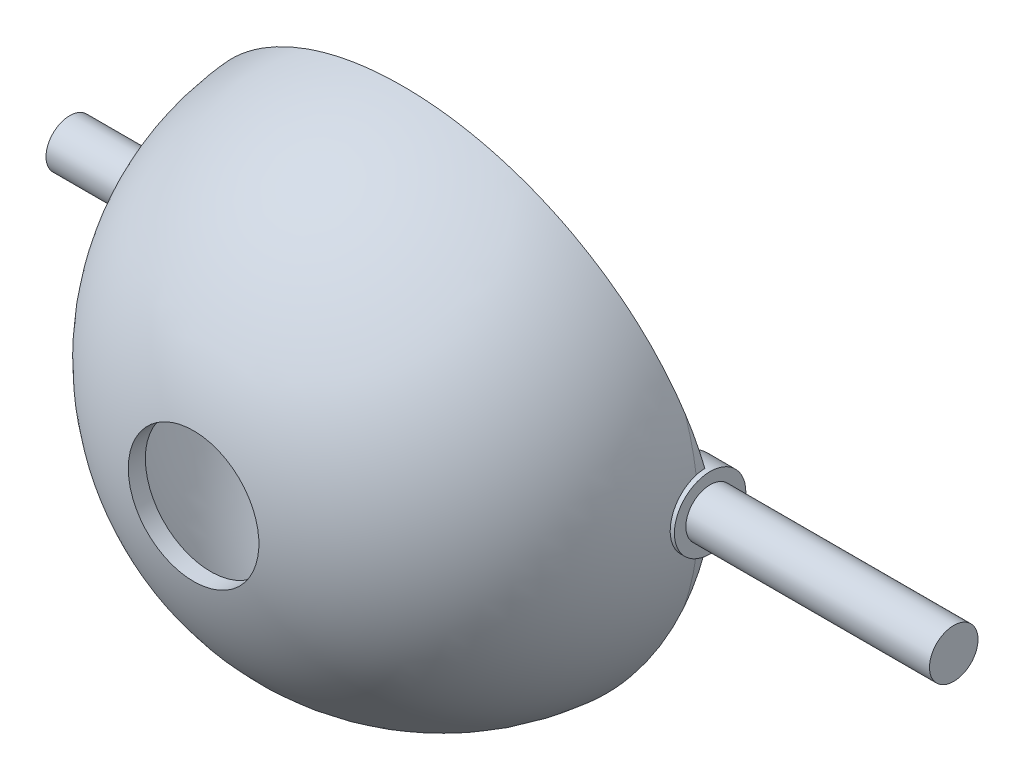
from build123d import *

# Parameters (mm, degrees)
SKETCH1_R                = 27.950000404747612
BOSS_EXTRUDE1_DEPTH      = 27.62022143637803
FILLET1_R                = 26.669999999999998
SHELL1_T                 = -1.778
SKETCH3_W                = 2.9777815367923886
SKETCH3_H                = 2.754447921533147
BOSS_EXTRUDE3_DEPTH      = 1.0160000000000005
BOSS_EXTRUDE4_DEPTH      = 25.790262530441638
BOSS_EXTRUDE4_DEPTH_BACK = 68.76087696461775
SKETCH4_R                = 3.820330599325679
SKETCH5_R                = 1.057927548072599
CUT_EXTRUDE1_DEPTH       = 74.422
SKETCH6_R                = 4.452679147341358
SKETCH6_R_2              = 2.5418565333404075
CUT_EXTRUDE2_DEPTH       = 12.446000000000002
SKETCH7_R                = 4.579796813302263
SKETCH7_R_2              = 2.5953263058571228
CUT_EXTRUDE3_DEPTH       = 26.058039102835256
CUT_EXTRUDE4_DEPTH       = 8.128000000000002
CUT_EXTRUDE4_DEPTH_BACK  = 4.571999999999997
SKETCH9_R                = 25.327508303904953
SKETCH10_R               = 6.985
CUT_EXTRUDE5_DEPTH       = 5.588
SKETCH11_R               = 0.9576542174699331
BOSS_EXTRUDE5_DEPTH      = 22.860000000000024
SKETCH12_R               = 3.048000000000001
BOSS_EXTRUDE6_DEPTH      = 11.36288626791476
BOSS_EXTRUDE6_2_DEPTH    = 11.36288626791476
SKETCH14_R               = 2.111885876285839
CUT_EXTRUDE6_DEPTH       = 33.27400000000001
CUT_EXTRUDE7_DEPTH       = 85.27832842042368
CUT_EXTRUDE8_DEPTH       = 91.8819256451622
BOSS_EXTRUDE7_DEPTH      = 4.3180000000000005
BOSS_EXTRUDE8_DEPTH      = 4.571999999999999


with BuildPart() as part:
    # Sketch1 → Boss-Extrude1 (new body)
    with BuildSketch(Plane.XY):
        Circle(SKETCH1_R)
    extrude(amount=BOSS_EXTRUDE1_DEPTH)

    # Fillet1
    fillet1_edges = [part.edges().sort_by_distance(p)[0] for p in [
        (-27.950000404747612, 3.42e-15, 27.62022143637803),
    ]]
    fillet(fillet1_edges, radius=FILLET1_R)

    # Shell1
    shell1_openings = [part.faces().sort_by_distance(p)[0] for p in [
        (0, 0, 0),
    ]]
    offset(amount=SHELL1_T, openings=shell1_openings, kind=Kind.INTERSECTION)

    # Sketch3 → Boss-Extrude3 (add)
    with BuildSketch(Plane(origin=(0, 0, 0), x_dir=(-1, 0, 0), z_dir=(0, 0, -1))):
        with Locations((-27.023367446390857, 0)):
            Rectangle(SKETCH3_W, SKETCH3_H)
    extrude(amount=BOSS_EXTRUDE3_DEPTH)

    # Sketch4 → Boss-Extrude4 (add, two sides: drawn at the far end of the back side and taken through both)
    with BuildSketch(Plane(origin=(28.51225821478705, 0, 0), x_dir=(0, 0, -1), z_dir=(1, 0, 0)).offset(-BOSS_EXTRUDE4_DEPTH_BACK)):
        Circle(SKETCH4_R)
    extrude(amount=BOSS_EXTRUDE4_DEPTH + BOSS_EXTRUDE4_DEPTH_BACK)

    # Sketch5 → Cut-Extrude1 (cut)
    with BuildSketch(Plane.ZY.offset(40.2486187498307)):
        Circle(SKETCH5_R)
    extrude(amount=-CUT_EXTRUDE1_DEPTH, mode=Mode.SUBTRACT)

    # Sketch6 → Cut-Extrude2 (cut)
    with BuildSketch(Plane.ZY.offset(40.2486187498307)):
        Circle(SKETCH6_R)
        Circle(SKETCH6_R_2, mode=Mode.SUBTRACT)
    extrude(amount=-CUT_EXTRUDE2_DEPTH, mode=Mode.SUBTRACT)

    # Sketch7 → Cut-Extrude3 (cut)
    with BuildSketch(Plane(origin=(54.30252074522868, 0, 0), x_dir=(0, 0, -1), z_dir=(1, 0, 0))):
        Circle(SKETCH7_R)
        Circle(SKETCH7_R_2, mode=Mode.SUBTRACT)
    extrude(amount=-CUT_EXTRUDE3_DEPTH, mode=Mode.SUBTRACT)

    # Sketch9 → Cut-Extrude4 (cut, two sides: drawn at the far end of the back side and taken through both)
    with BuildSketch(Plane(origin=(0, 0, 0), x_dir=(-1, 0, 0), z_dir=(0, 0, -1)).offset(-CUT_EXTRUDE4_DEPTH_BACK)):
        Circle(SKETCH9_R)
    extrude(amount=CUT_EXTRUDE4_DEPTH + CUT_EXTRUDE4_DEPTH_BACK, mode=Mode.SUBTRACT)

    # Sketch10 → Cut-Extrude5 (cut)
    with BuildSketch(Plane.XY.offset(27.62022143637803)):
        with Locations(Location((0, 0, 0), (0, 0, 180))):
            Circle(SKETCH10_R)
    extrude(amount=-CUT_EXTRUDE5_DEPTH, mode=Mode.SUBTRACT)

    # Sketch15 → Cut-Extrude7 (cut)
    with BuildSketch(Plane(origin=(54.30252074522868, 0, 0), x_dir=(0, 0, -1), z_dir=(1, 0, 0))):
        Polygon((-1.334e-14, 3.8203305993256875), (-4.891274508363616, 29.145036791355672), (1.6598448725796273, 29.145036791355672), align=None)
    extrude(amount=-CUT_EXTRUDE7_DEPTH, mode=Mode.SUBTRACT)

    # Sketch16 → Cut-Extrude8 (cut)
    with BuildSketch(Plane(origin=(54.30252074522868, 0, 0), x_dir=(0, 0, -1), z_dir=(1, 0, 0))):
        Polygon((0, -3.820330599325679), (-4.288923829809152, -28.486260213313365), (3.8203305993256866, -28.486260213313365), align=None)
    extrude(amount=-CUT_EXTRUDE8_DEPTH, mode=Mode.SUBTRACT)



with BuildPart() as body_2:
    # Sketch11 → Boss-Extrude5 (new body)
    with BuildSketch(Plane.XY.offset(27.00289653161864)):
        Circle(SKETCH11_R)
    extrude(amount=-BOSS_EXTRUDE5_DEPTH)

    # Sketch14 → Cut-Extrude6 (cut)
    with BuildSketch(Plane(origin=(0, 0, 0), x_dir=(-1, 0, 0), z_dir=(0, 0, -1))):
        Circle(SKETCH14_R)
    extrude(amount=-CUT_EXTRUDE6_DEPTH, mode=Mode.SUBTRACT)


with BuildPart() as body_3:
    # Sketch12 → Boss-Extrude6 (new body)
    with BuildSketch(Plane(origin=(0, 0, 4.142896531618617), x_dir=(-1, 0, 0), z_dir=(0, 0, -1))):
        with Locations((11.937999999999999, 16.638354336827483)):
            Circle(SKETCH12_R)
    extrude(amount=-BOSS_EXTRUDE6_DEPTH)


with BuildPart() as body_4:
    # Sketch12 → Boss-Extrude6 2 (new body)
    with BuildSketch(Plane(origin=(0, 0, 4.142896531618617), x_dir=(-1, 0, 0), z_dir=(0, 0, -1))):
        with Locations((-11.953495285116952, -16.63835433682737)):
            Circle(SKETCH12_R)
    extrude(amount=-BOSS_EXTRUDE6_2_DEPTH)


with BuildPart() as part_1:
    add(part.part)

    add(body_3.part)  # Boss-Extrude7 merges body 3
    # Sketch17 → Boss-Extrude7 (add)
    with BuildSketch(Plane(origin=(0, 0, 4.142896531618617), x_dir=(-1, 0, 0), z_dir=(0, 0, -1))):
        Polygon((9.771876580523754, 18.78269883610845), (13.319873488272151, 22.366730868249395), (14.06110283418301, 21.919031525548853), (14.604654174308786, 15.162122812085675), align=None)
    extrude(amount=-BOSS_EXTRUDE7_DEPTH)


    add(body_4.part)  # Boss-Extrude8 merges body 4
    # Sketch18 → Boss-Extrude8 (add)
    with BuildSketch(Plane(origin=(0, 0, 4.142896531618617), x_dir=(-1, 0, 0), z_dir=(0, 0, -1))):
        Polygon((-14.460459528143115, -14.90473549631246), (-17.767050171841895, -19.686354336827367), (-12.919801099290412, -22.635936934230834), (-9.44653104209079, -18.37197317734228), align=None)
    extrude(amount=-BOSS_EXTRUDE8_DEPTH)


solid = part_1.part
